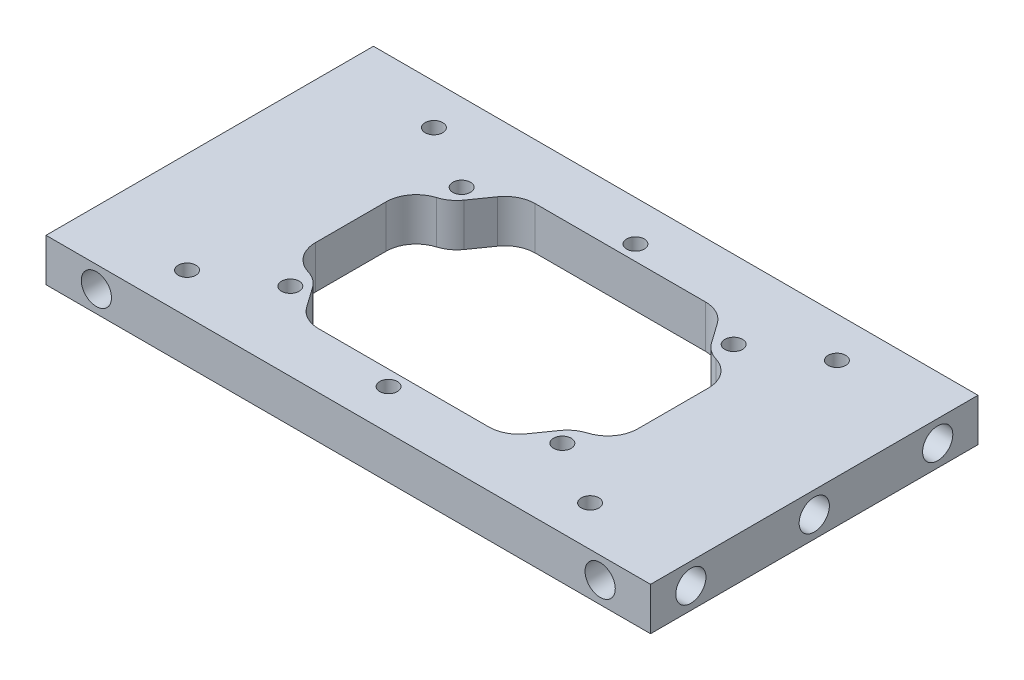
from build123d import *

# Parameters (mm, degrees)
SKETCH1_W                      = 65
SKETCH1_H                      = 8.5
BOSS_EXTRUDE1_DEPTH            = 120
F_6_0MM_DOWEL_HOLE1_AT_2_COUNT = 2
F_6_0MM_DOWEL_HOLE1_AT_2_PITCH = 24.5
F_6_0MM_DOWEL_HOLE1_AT_3_COUNT = 2
F_6_0MM_DOWEL_HOLE1_AT_3_PITCH = 49
F_6_0MM_DOWEL_HOLE2_AT_2_COUNT = 2
F_6_0MM_DOWEL_HOLE2_AT_2_PITCH = 100
CUT_EXTRUDE1_DEPTH             = 9.5
F_3_0MM_DOWEL_HOLE1_D          = 3.5
CUT_EXTRUDE2_DEPTH             = 9.5
FILLET1_R                      = 6


with BuildPart() as part:
    # Sketch1 → Boss-Extrude1 (new body)
    with BuildSketch(Plane(origin=(0, 0, 0), x_dir=(0, 0, -1), z_dir=(1, 0, 0))):
        Rectangle(SKETCH1_W, SKETCH1_H)
    extrude(amount=BOSS_EXTRUDE1_DEPTH)

    # Sketch3 → Ø6.0mm Dowel Hole1 (revolve, cut)
    with BuildSketch(Plane(origin=(120, 0, 24.5), x_dir=(0, 0, -1), z_dir=(0, 1, 0))):
        Polygon((0, 0), (0, 11.802581857), (3, 10), (3, 0), align=None)
    f_6_0mm_dowel_hole1 = revolve(axis=Axis((126.35, 0, 24.5), (-1, 0, 0)), mode=Mode.SUBTRACT)

    # Ø6.0mm Dowel Hole1 at 2: Ø6.0mm Dowel Hole1 ×2
    with Locations(*[(0, 0, -i * F_6_0MM_DOWEL_HOLE1_AT_2_PITCH) for i in range(1, F_6_0MM_DOWEL_HOLE1_AT_2_COUNT)]):
        add(f_6_0mm_dowel_hole1, mode=Mode.SUBTRACT)

    # Ø6.0mm Dowel Hole1 at 3: Ø6.0mm Dowel Hole1 ×2
    with Locations(*[(0, 0, -i * F_6_0MM_DOWEL_HOLE1_AT_3_PITCH) for i in range(1, F_6_0MM_DOWEL_HOLE1_AT_3_COUNT)]):
        add(f_6_0mm_dowel_hole1, mode=Mode.SUBTRACT)

    # Mirror1: Ø6.0mm Dowel Hole1 across plane
    add(f_6_0mm_dowel_hole1.mirror(Plane(origin=(60, 0, 0), x_dir=(0, 0, 1), z_dir=(1, 0, 0))), mode=Mode.SUBTRACT)

    # Mirror1 copy 1 sketch → Mirror1 copy 1 (revolve, cut)
    with BuildSketch(Plane(origin=(0, 0, 0), x_dir=(0, 0, -1), z_dir=(0, 1, 0))):
        Polygon((0, 0), (0, -11.802581857), (3, -10), (3, 0), align=None)
    revolve(axis=Axis((-6.35, 0, 0), (-1, 0, 0)), mode=Mode.SUBTRACT)

    # Mirror1 copy 2 sketch → Mirror1 copy 2 (revolve, cut)
    with BuildSketch(Plane(origin=(0, 0, -24.5), x_dir=(0, 0, -1), z_dir=(0, 1, 0))):
        Polygon((0, 0), (0, -11.802581857), (3, -10), (3, 0), align=None)
    revolve(axis=Axis((-6.35, 0, -24.5), (-1, 0, 0)), mode=Mode.SUBTRACT)

    # Sketch5 → Ø6.0mm Dowel Hole2 (revolve, cut)
    with BuildSketch(Plane(origin=(110, 0, -32.5), x_dir=(0, 1, 0), z_dir=(1, 0, 0))):
        Polygon((0, 0), (0, 9.802581857), (3, 8), (3, 0), align=None)
    f_6_0mm_dowel_hole2 = revolve(axis=Axis((110, 0, -38.85), (0, 0, 1)), mode=Mode.SUBTRACT)

    # Ø6.0mm Dowel Hole2 at 2: Ø6.0mm Dowel Hole2 ×2
    with Locations(*[(-i * F_6_0MM_DOWEL_HOLE2_AT_2_PITCH, 0, 0) for i in range(1, F_6_0MM_DOWEL_HOLE2_AT_2_COUNT)]):
        add(f_6_0mm_dowel_hole2, mode=Mode.SUBTRACT)

    # Mirror2: Ø6.0mm Dowel Hole2 across plane
    add(f_6_0mm_dowel_hole2.mirror(Plane.XY), mode=Mode.SUBTRACT)

    # Mirror2 copy 1 sketch → Mirror2 copy 1 (revolve, cut)
    with BuildSketch(Plane(origin=(10, 0, 32.5), x_dir=(0, 1, 0), z_dir=(1, 0, 0))):
        Polygon((0, 0), (0, -9.802581857), (3, -8), (3, 0), align=None)
    revolve(axis=Axis((10, 0, 38.85), (0, 0, 1)), mode=Mode.SUBTRACT)

    # Sketch6 → Cut-Extrude1 (cut, through all)
    with BuildSketch(Plane(origin=(0, 4.25, 0), x_dir=(1, 0, 0), z_dir=(0, 1, 0))):
        with BuildLine():
            Line((80, -7), (80, 7))
            ThreePointArc((80, 7), (86, 13), (92, 7))
            Line((92, 7), (92, -7))
            ThreePointArc((92, -7), (86, -13), (80, -7))
        make_face()
    cut_extrude1 = extrude(amount=-CUT_EXTRUDE1_DEPTH, mode=Mode.SUBTRACT)

    # Mirror3: Cut-Extrude1 across plane
    add(cut_extrude1.mirror(Plane(origin=(60, 0, 0), x_dir=(0, 0, 1), z_dir=(1, 0, 0))), mode=Mode.SUBTRACT)

    # Ø3.0mm Dowel Hole1 (through all)
    with Locations(Plane(origin=(0, 4.25, 0), x_dir=(1, 0, 0), z_dir=(0, 1, 0))):
        with Locations((87, -17), (87, 17), (33, 17), (33, -17), (100, -24.5), (60, -24.5), (20, -24.5), (100, 24.5), (60, 24.5), (20, 24.5)):
            Hole(F_3_0MM_DOWEL_HOLE1_D / 2)

    # Sketch10 → Cut-Extrude2 (cut, through all)
    with BuildSketch(Plane.XZ.offset(4.25)):
        with BuildLine():
            ThreePointArc((34, 13), (38.242640687, 11.242640687), (40, 7))
            Line((40, 7), (40, 21.5))
            Line((40, 21.5), (34, 13))
        make_face()
        Polygon((40, -7), (40, -21.5), (80, -21.5), (80, -7), (80, 7), (80, 21.5), (40, 21.5), (40, 7), align=None)
        with BuildLine():
            Line((34, -13), (40, -21.5))
            Line((40, -21.5), (40, -7))
            ThreePointArc((40, -7), (38.242640687, -11.242640687), (34, -13))
        make_face()
        with BuildLine():
            Line((80, 21.5), (80, 7))
            ThreePointArc((80, 7), (81.757359313, 11.242640687), (86, 13))
            Line((86, 13), (80, 21.5))
        make_face()
        with BuildLine():
            Line((80, -7), (80, -21.5))
            Line((80, -21.5), (86, -13))
            ThreePointArc((86, -13), (81.757359313, -11.242640687), (80, -7))
        make_face()
    extrude(amount=-CUT_EXTRUDE2_DEPTH, mode=Mode.SUBTRACT)

    # Fillet1
    fillet1_edges = [part.edges().sort_by_distance(p)[0] for p in [
        (34, 0, 13),
        (40, 0, 21.5),
        (80, 0, 21.5),
        (86, 0, 13),
        (86, 0, -13),
        (80, 0, -21.5),
        (40, 0, -21.5),
        (34, 0, -13),
    ]]
    fillet(fillet1_edges, radius=FILLET1_R)


solid = part.part
